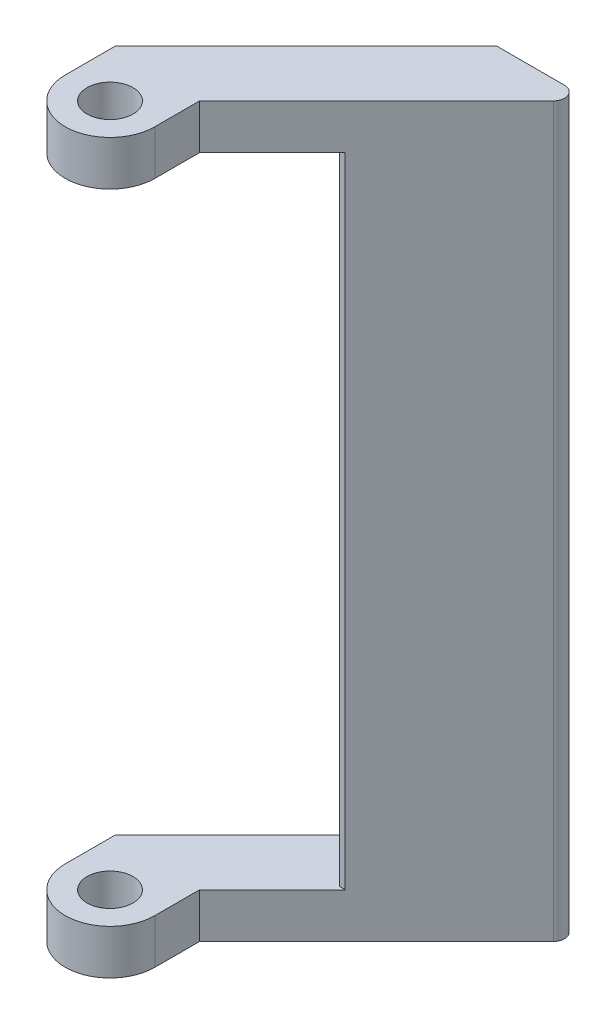
from build123d import *

# Parameters (mm, degrees)
BOSS_EXTRUDE1_DEPTH            = 4.00000003
BOSS_EXTRUDE2_DEPTH            = 56.99999997
BOSS_EXTRUDE3_DEPTH            = 4
F_4_1_4_1_DIAMETER_HOLE1_D     = 4.1
F_4_1_4_1_DIAMETER_HOLE1_DEPTH = 4
F_4_1_4_1_DIAMETER_HOLE2_D     = 4.1
F_4_1_4_1_DIAMETER_HOLE2_DEPTH = 65


with BuildPart() as part:
    # Sketch1 → Boss-Extrude1 (new body)
    with BuildSketch(Plane.XZ.offset(61.6)):
        with BuildLine():
            Line((-25.5, 17.014718626), (-8.485281374, 0))
            Line((-8.485281374, 0), (-2.414213562, 0))
            ThreePointArc((-2.414213562, 0), (-1.49033403, 0.617316568), (-1.707106781, 1.707106781))
            Line((-1.707106781, 1.707106781), (-17.5, 17.5))
            Line((-17.5, 17.5), (-17.5, 21.5))
            ThreePointArc((-17.5, 21.5), (-21.5, 25.5), (-25.5, 21.5))
            Line((-25.5, 21.5), (-25.5, 17.014718626))
        make_face()
    extrude(amount=-BOSS_EXTRUDE1_DEPTH)

    # Sketch2 → Boss-Extrude2 (add)
    with BuildSketch(Plane(origin=(0, -57.59999997, 0), x_dir=(-1, 0, 0), z_dir=(0, 1, 0))):
        with BuildLine():
            Line((1.707106781, 1.707106781), (11.000000003, 11.000000003))
            Line((11.000000003, 11.000000003), (11.500000002, 11.000000003))
            Line((11.500000002, 11.000000003), (11.500000002, 3.014718628))
            Line((11.500000002, 3.014718628), (8.485281374, 0))
            Line((8.485281374, 0), (2.414213562, 0))
            ThreePointArc((2.414213562, 0), (1.49033403, 0.617316568), (1.707106781, 1.707106781))
        make_face()
    extrude(amount=BOSS_EXTRUDE2_DEPTH)

    # Sketch3 → Boss-Extrude3 (add)
    with BuildSketch(Plane(origin=(0, -0.6, 0), x_dir=(-1, 0, 0), z_dir=(0, 1, 0))):
        with BuildLine():
            Line((8.485281374, 0), (2.414213562, 0))
            ThreePointArc((2.414213562, 0), (1.49033403, 0.617316568), (1.707106781, 1.707106781))
            Line((1.707106781, 1.707106781), (17.500000001, 17.500000001))
            Line((17.500000001, 17.500000001), (17.500000001, 21.5))
            ThreePointArc((17.500000001, 21.5), (21.500000001, 25.5), (25.5, 21.5))
            Line((25.5, 21.5), (25.5, 17.014718626))
            Line((25.5, 17.014718626), (8.485281374, 0))
        make_face()
    extrude(amount=BOSS_EXTRUDE3_DEPTH)

    # Ø4.1 (4.1) Diameter Hole1
    with Locations(Plane(origin=(0, 3.4, 0), x_dir=(1, 0, 0), z_dir=(0, 1, 0))):
        with Locations((-21.5, -21.5)):
            Hole(F_4_1_4_1_DIAMETER_HOLE1_D / 2, depth=F_4_1_4_1_DIAMETER_HOLE1_DEPTH)

    # Ø4.1 (4.1) Diameter Hole2
    with Locations(Plane(origin=(0, -61.6, 0), x_dir=(-1, 0, 0), z_dir=(0, -1, 0))):
        with Locations((21.5, -21.5)):
            Hole(F_4_1_4_1_DIAMETER_HOLE2_D / 2, depth=F_4_1_4_1_DIAMETER_HOLE2_DEPTH)


solid = part.part
